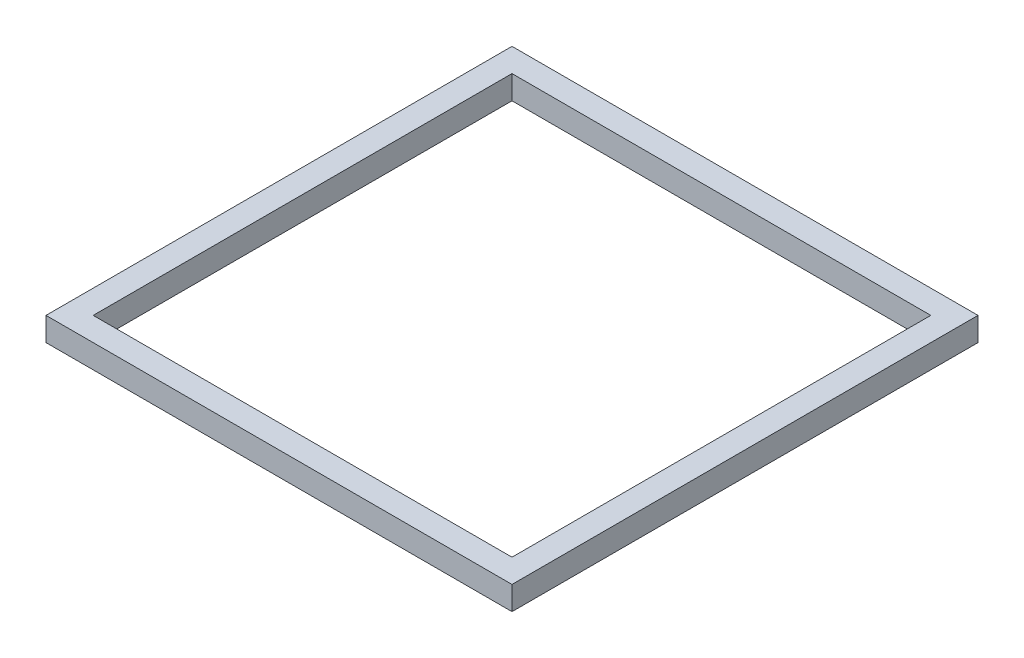
from build123d import *

# Parameters (mm, degrees)
SKETCH1_W           = 125.4
SKETCH1_H           = 125.4
BOSS_EXTRUDE1_DEPTH = 6.35
SKETCH2_W           = 112.7
SKETCH2_H           = 112.7
CUT_EXTRUDE1_DEPTH  = 7.35


with BuildPart() as part:
    # Sketch1 → Boss-Extrude1 (new body)
    with BuildSketch(Plane(origin=(0, 0, 0), x_dir=(1, 0, 0), z_dir=(0, 1, 0))):
        Rectangle(SKETCH1_W, SKETCH1_H)
    extrude(amount=BOSS_EXTRUDE1_DEPTH)

    # Sketch2 → Cut-Extrude1 (cut, through all)
    with BuildSketch(Plane(origin=(0, 6.35, 0), x_dir=(1, 0, 0), z_dir=(0, 1, 0))):
        Rectangle(SKETCH2_W, SKETCH2_H)
    extrude(amount=-CUT_EXTRUDE1_DEPTH, mode=Mode.SUBTRACT)


solid = part.part
